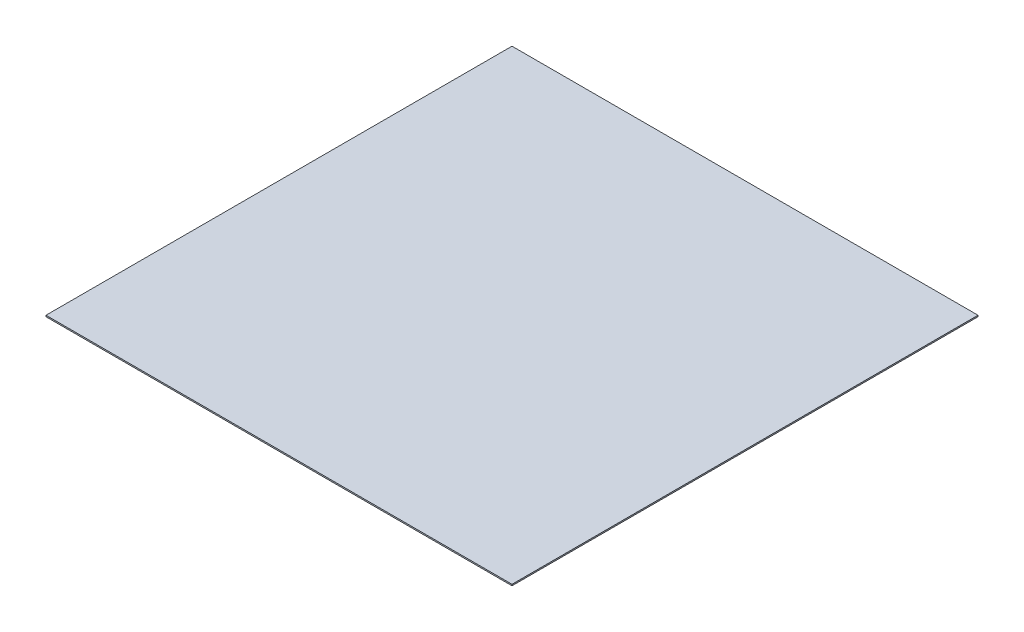
from build123d import *

# Parameters (mm, degrees)
SZKIC1_W                    = 345
SZKIC1_H                    = 345
DODANIE_WYCI_GNI_CIE1_DEPTH = 1


with BuildPart() as part:
    # Szkic1 → Dodanie-wyciągnięcie1 (new body)
    with BuildSketch(Plane(origin=(0, 0, 0), x_dir=(1, 0, 0), z_dir=(0, 1, 0))):
        with Locations((172.5, -172.5)):
            Rectangle(SZKIC1_W, SZKIC1_H)
    extrude(amount=DODANIE_WYCI_GNI_CIE1_DEPTH)


solid = part.part
